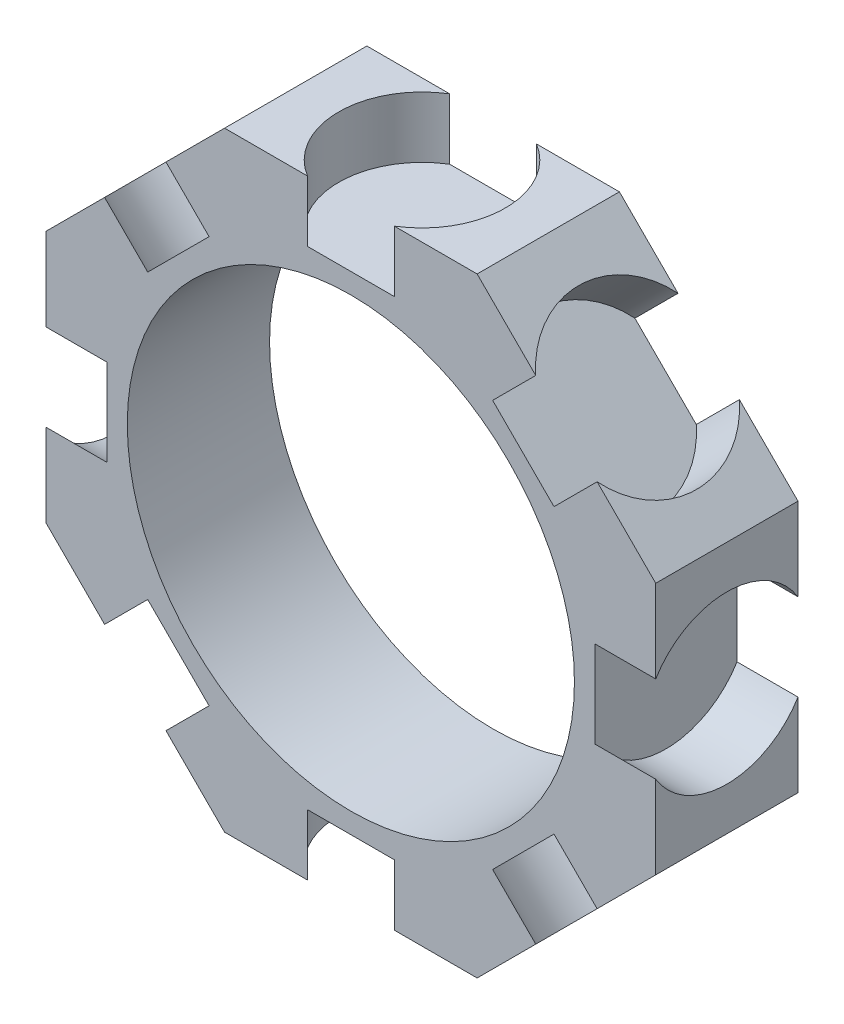
from build123d import *

# Parameters (mm, degrees)
SKETCH1_R           = 11
BOSS_EXTRUDE1_DEPTH = 3.5
SKETCH2_R           = 4.1
CUT_EXTRUDE3_DEPTH  = 3
CIRPATTERN1_COUNT   = 8


with BuildPart() as part:
    # Sketch1 → Boss-Extrude1 (new, symmetric)
    with BuildSketch(Plane.XY):
        Polygon((6.213203436, 15), (-6.213203436, 15), (-15, 6.213203436), (-15, -6.213203436), (-6.213203436, -15), (6.213203436, -15), (15, -6.213203436), (15, 6.213203436), align=None)
        Circle(SKETCH1_R, mode=Mode.SUBTRACT)
    extrude(amount=BOSS_EXTRUDE1_DEPTH, both=True)

    # Sketch2 → Cut-Extrude3 (cut)
    with BuildSketch(Plane(origin=(0, -15, 0), x_dir=(-1, 0, 0), z_dir=(0, -1, 0))):
        Circle(SKETCH2_R)
    cut_extrude3 = extrude(amount=-CUT_EXTRUDE3_DEPTH, mode=Mode.SUBTRACT)

    # CirPattern1: Cut-Extrude3 ×8 about axis
    cirpattern1_axis = Axis((0, 0, 3.5), (0, 0, 1))
    for i in range(1, CIRPATTERN1_COUNT):
        add(cut_extrude3.rotate(cirpattern1_axis, i * 360 / CIRPATTERN1_COUNT), mode=Mode.SUBTRACT)


solid = part.part
